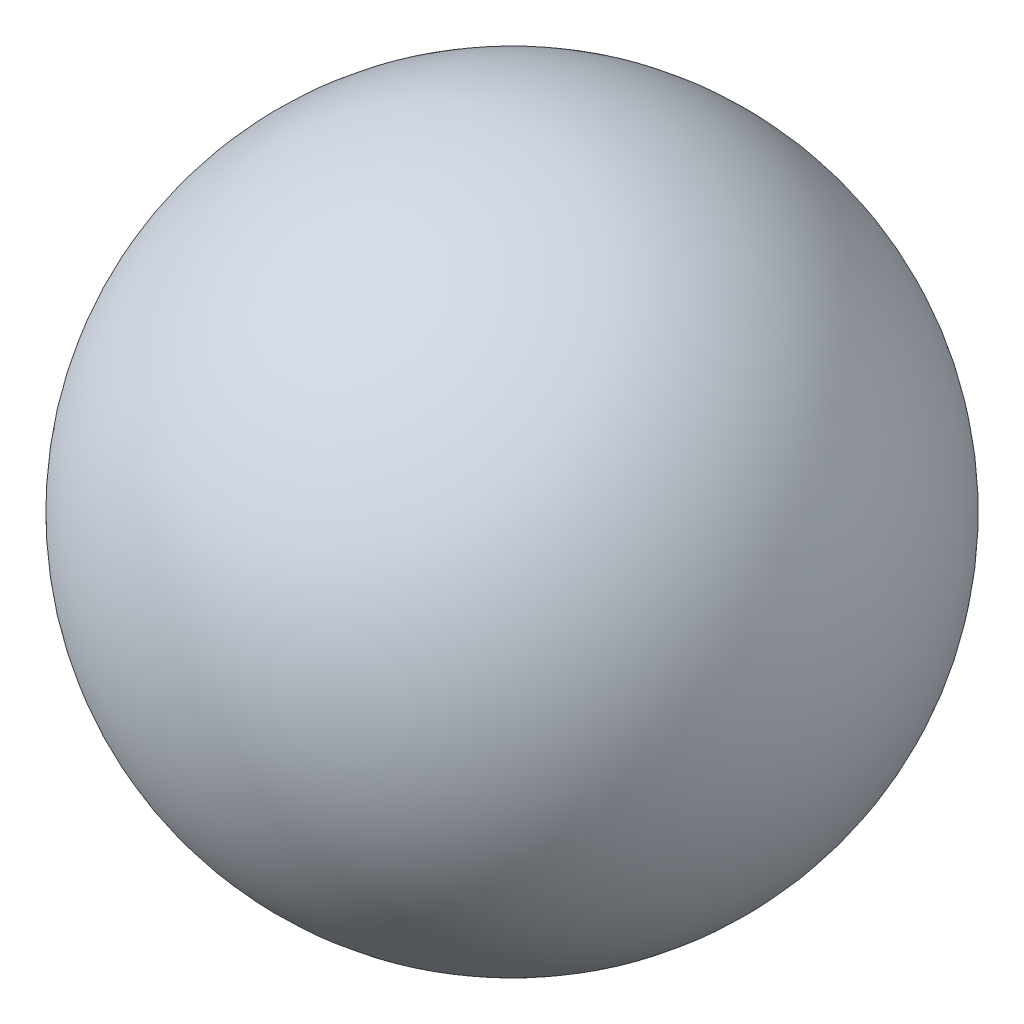
from build123d import *


with BuildPart() as part:
    # Sketch1 → Revolve1 (revolve)
    with BuildSketch(Plane.XY):
        with BuildLine():
            Line((0, 40), (0, 39.458))
            ThreePointArc((0, 39.458), (19.458, 20), (0, 0.542))
            Line((0, 0.542), (0, 0))
            ThreePointArc((0, 0), (20, 20), (0, 40))
        make_face()
    revolve(axis=Axis((0, 40, 0), (0, -1, 0)))


solid = part.part
